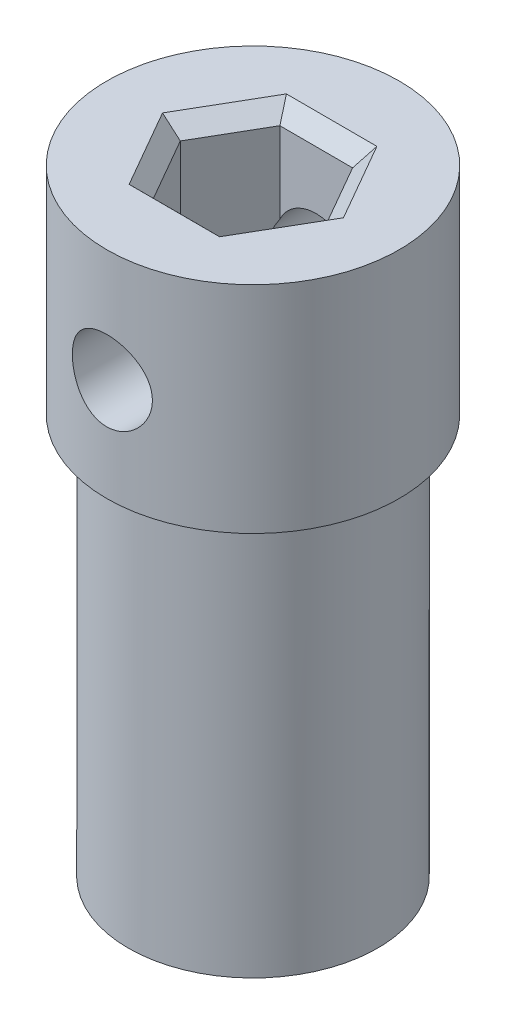
from build123d import *

# Parameters (mm, degrees)
SKETCH1_R           = 4.05
BOSS_EXTRUDE1_DEPTH = 20
BOSS_EXTRUDE2_DEPTH = 5
SKETCH3_R           = 4.75
SKETCH3_R_2         = 4.05
BOSS_EXTRUDE3_DEPTH = 7
CHAMFER1_SIZE       = 0.5
SKETCH4_R           = 1.3
CUT_EXTRUDE1_DEPTH  = 10.5


with BuildPart() as part:
    # Sketch1 → Boss-Extrude1 (new body)
    with BuildSketch(Plane(origin=(0, 0, 0), x_dir=(1, 0, 0), z_dir=(0, 1, 0))):
        Circle(SKETCH1_R)
        Polygon((1.187868906, 2.047510878), (-1.179261982, 2.052480088), (-2.367130888, 0.00496921), (-1.187868906, -2.047510878), (1.179261982, -2.052480088), (2.367130888, -0.00496921), align=None, mode=Mode.SUBTRACT)
    extrude(amount=BOSS_EXTRUDE1_DEPTH)

    # Sketch2 → Boss-Extrude2 (add)
    with BuildSketch(Plane.XZ):
        Polygon((1.187868906, -2.047510878), (2.367130888, 0.00496921), (1.179261982, 2.052480088), (-1.187868906, 2.047510878), (-2.367130888, -0.00496921), (-1.179261982, -2.052480088), align=None)
    extrude(amount=-BOSS_EXTRUDE2_DEPTH)

    # Sketch3 → Boss-Extrude3 (add)
    with BuildSketch(Plane(origin=(0, 13, 0), x_dir=(-1, 0, 0), z_dir=(0, -1, 0))):
        Circle(SKETCH3_R)
        Circle(SKETCH3_R_2, mode=Mode.SUBTRACT)
    extrude(amount=-BOSS_EXTRUDE3_DEPTH)

    # Chamfer1
    chamfer1_edges = [part.edges().sort_by_distance(p)[0] for p in [
        (1.777499897, 20, -1.021270834),
        (0.004303462, 20, -2.049995483),
        (-1.773196435, 20, -1.028724649),
        (-1.777499897, 20, 1.021270834),
        (-0.004303462, 20, 2.049995483),
        (1.773196435, 20, 1.028724649),
    ]]
    chamfer(chamfer1_edges, length=CHAMFER1_SIZE)

    # Sketch4 → Cut-Extrude1 (cut, through all)
    with BuildSketch(Plane(origin=(0, 0, -4.75), x_dir=(-1, 0, 0), z_dir=(0, 0, -1))):
        with Locations((0, 16.319152566)):
            Circle(SKETCH4_R)
    extrude(amount=-CUT_EXTRUDE1_DEPTH, mode=Mode.SUBTRACT)


solid = part.part
